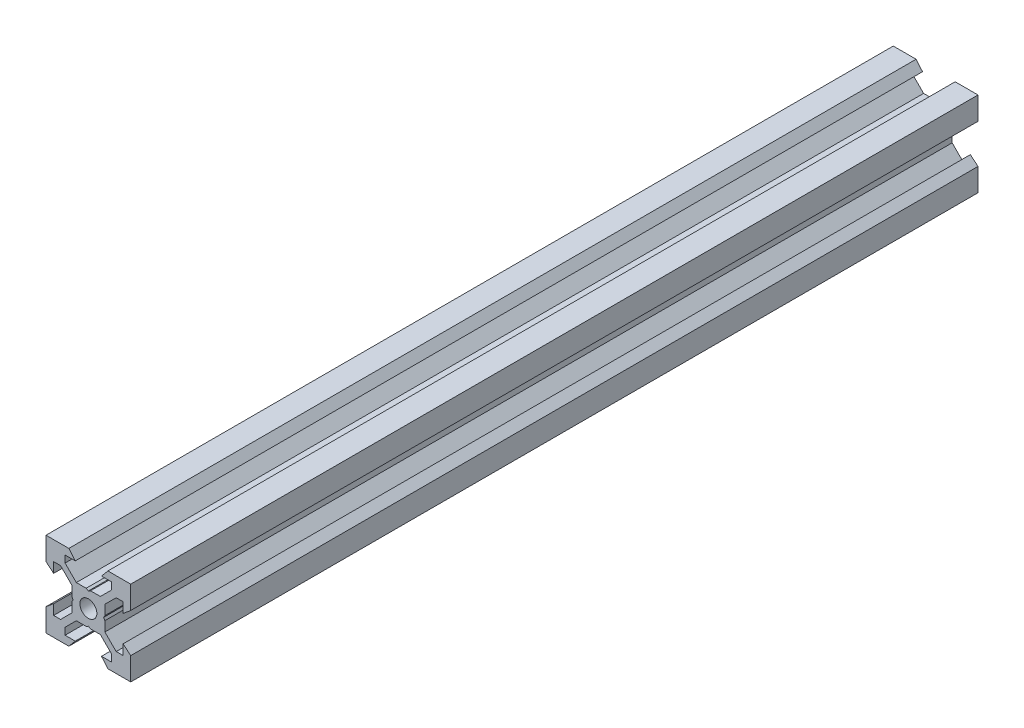
from build123d import *

# Parameters (mm, degrees)
SKETCH1_R           = 2
BOSS_EXTRUDE1_DEPTH = 100


with BuildPart() as part:
    # Sketch1 → Boss-Extrude1 (new body, symmetric)
    with BuildSketch(Plane.XY):
        Polygon((10, 10), (10, 4.610379336), (8.2, 3.1), (8.2, 5.5), (6.560660172, 5.5), (3.9, 2.839339828), (3.9, 0.519615242), (3.6, 0), (3.9, -0.519615242), (3.9, -2.839339828), (6.560660172, -5.5), (8.2, -5.5), (8.2, -3.1), (10, -4.610379336), (10, -10), (4.610379336, -10), (3.1, -8.2), (5.5, -8.2), (5.5, -6.560660172), (2.839339828, -3.9), (0.519615242, -3.9), (0, -3.6), (-0.519615242, -3.9), (-2.839339828, -3.9), (-5.5, -6.560660172), (-5.5, -8.2), (-3.1, -8.2), (-4.610379336, -10), (-10, -10), (-10, -4.610379336), (-8.2, -3.1), (-8.2, -5.5), (-6.560660172, -5.5), (-3.9, -2.839339828), (-3.9, -0.519615242), (-3.6, 0), (-3.9, 0.519615242), (-3.9, 2.839339828), (-6.560660172, 5.5), (-8.2, 5.5), (-8.2, 3.1), (-10, 4.610379336), (-10, 10), (-4.610379336, 10), (-3.1, 8.2), (-5.5, 8.2), (-5.5, 6.560660172), (-2.839339828, 3.9), (-0.519615242, 3.9), (0, 3.6), (0.519615242, 3.9), (2.839339828, 3.9), (5.5, 6.560660172), (5.5, 8.2), (3.1, 8.2), (4.610379336, 10), align=None)
        Circle(SKETCH1_R, mode=Mode.SUBTRACT)
    extrude(amount=BOSS_EXTRUDE1_DEPTH, both=True)


solid = part.part
